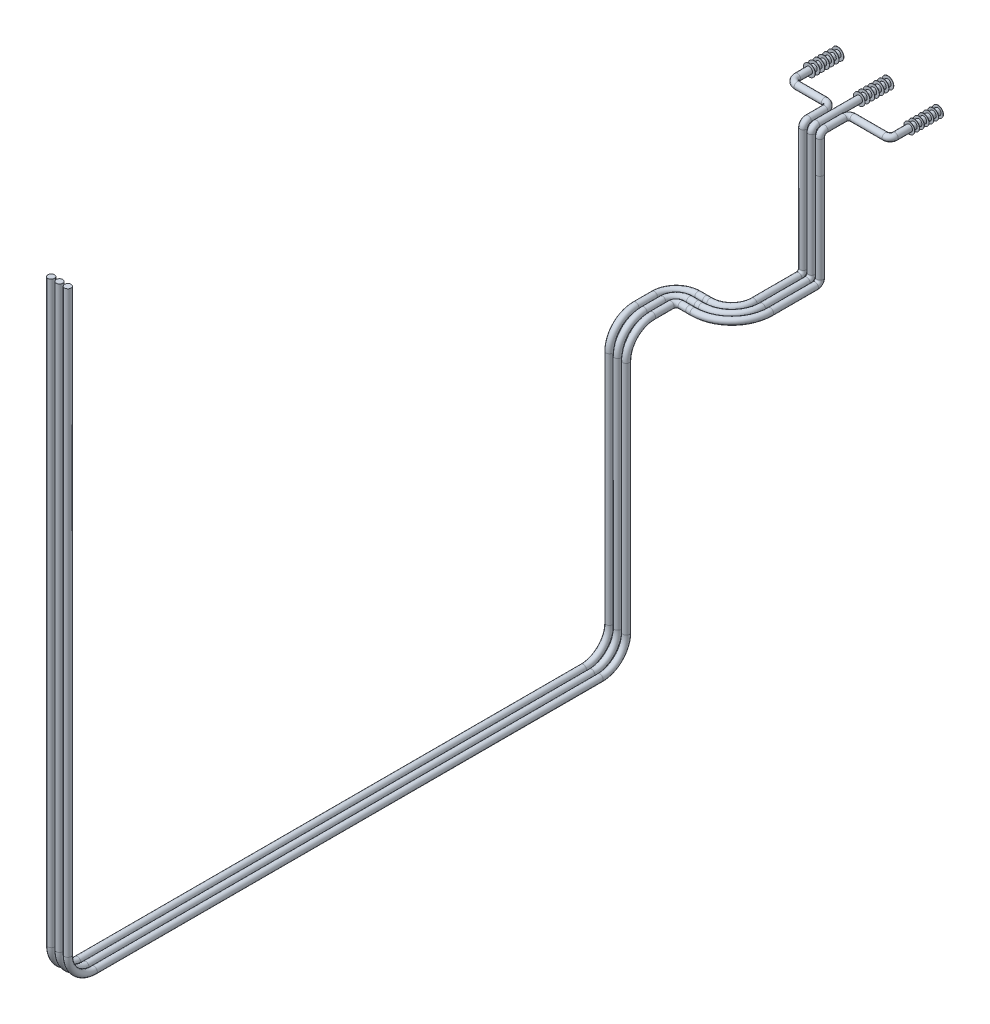
from build123d import *

# Parameters (mm, degrees)
BARRER5_PROFILE_R       = 13.7
BARRER6_PROFILE_R       = 13.7
CROQUIS41_R             = 13.7
CROQUIS62_R             = 22.870183784
CROQUIS62_R_2           = 24.36570856
CROQUIS62_R_3           = 24.738020287
SALIENTE_EXTRUIR1_DEPTH = 1
MATRIZL1_COUNT          = 7
MATRIZL1_PITCH          = 20
CROQUIS64_W             = 239.066100256
CROQUIS64_H             = 33.201144274
CORTAR_EXTRUIR1_DEPTH   = 5
CROQUIS65_R             = 13.7
CROQUIS65_R_2           = 13.697033


with BuildPart() as part:
    # Barrer5: sweep along a curve in space
    with BuildLine() as barrer5_path:
        Line((0, 0, 0), (0, 0, 170))
        ThreePointArc((0, 0, 170), (8.786796564, 0, 191.213203436), (30, 0, 200))
        Line((30, 0, 200), (145.00018, 0, 200))
        ThreePointArc((145.00018, 0, 200), (166.213383436, 0, 208.786796564), (175.00018, 0, 230))
        Line((175.00018, 0, 230), (175.00018, 0, 300))
        ThreePointArc((175.00018, 0, 300), (175.00018, -5.857864376, 314.142135624), (175.00018, -20, 320))
        Line((175.00018, -20, 320), (175.00018, -156.800061359, 320))
    # Barrer5 profile (on start of the path) → Barrer5 (sweep)
    with BuildSketch(Plane.XY):
        Circle(BARRER5_PROFILE_R)
    sweep(path=barrer5_path.line)


with BuildPart() as body_2:
    # Barrer6: sweep along a curve in space
    with BuildLine() as barrer6_path:
        Line((210, 0, 0), (210, 0, 299.997033))
        ThreePointArc((210, 0, 299.997033), (210, -5.857864376, 314.139168624), (210, -20, 319.997033))
        Line((210, -20, 319.997033), (210, -153.425324093, 319.997033))
    # Barrer6 profile (on start of the path) → Barrer6 (sweep)
    with BuildSketch(Plane(origin=(210, 0, 0), x_dir=(1, 0, 0), z_dir=(0, 0, 1))):
        Circle(BARRER6_PROFILE_R)
    sweep(path=barrer6_path.line)


with BuildPart() as body_3:
    # Barrer7: sweep along a curve in space
    with BuildLine() as barrer7_path:
        Line((420, 0, 0), (420, 0, 180))
        ThreePointArc((420, 0, 180), (414.142135624, 0, 194.142135624), (400, 0, 200))
        Line((400, 0, 200), (264.998005, 0, 200))
        ThreePointArc((264.998005, 0, 200), (250.855869376, 0, 205.857864376), (244.998005, 0, 220))
        Line((244.998005, 0, 220), (244.998005, 0, 300))
        ThreePointArc((244.998005, 0, 300), (244.998005, -5.857864376, 314.142135624), (244.998005, -20, 320))
        Line((244.998005, -20, 320), (244.998005, -158.814937218, 320))
    # Croquis41 → Barrer7 (sweep)
    with BuildSketch(Plane(origin=(0, 0, 0), x_dir=(-1, 0, 0), z_dir=(0, 0, -1))):
        with Locations((-420, 0)):
            Circle(CROQUIS41_R)
    sweep(path=barrer7_path.line)

    # Croquis62 → Saliente-Extruir1 (add)
    with BuildSketch(Plane(origin=(0, 0, 0), x_dir=(-1, 0, 0), z_dir=(0, 0, -1))):
        with Locations((-420, 0)):
            Circle(CROQUIS62_R)
        with Locations((-210, 0)):
            Circle(CROQUIS62_R_2)
        Circle(CROQUIS62_R_3)
    saliente_extruir1 = extrude(amount=SALIENTE_EXTRUIR1_DEPTH)


with BuildPart() as saliente_extruir1_piece_1:
    # of the separate pieces the step leaves, piece 1, a body of its own (saliente_extruir1_pieces)
    add(body_3.part.solids().sort_by_distance((397.129816216, 0, 0))[0])


with BuildPart() as saliente_extruir1_piece_2:
    # of the separate pieces the step leaves, piece 2, a body of its own (saliente_extruir1_pieces)
    add(body_3.part.solids().sort_by_distance((-24.738020287, 0, 0))[0])


with BuildPart() as saliente_extruir1_piece_3:
    # of the separate pieces the step leaves, piece 3, a body of its own (saliente_extruir1_pieces)
    add(body_3.part.solids().sort_by_distance((185.63429144, 0, 0))[0])


with BuildPart() as part_1:
    add(part.part)

    add(body_2.part)  # MatrizL1 merges body 2

    add(saliente_extruir1_piece_1.part)  # MatrizL1 merges Saliente-Extruir1 piece 1
    # MatrizL1: Saliente-Extruir1 ×7
    with Locations(*[(0, 0, i * MATRIZL1_PITCH) for i in range(1, MATRIZL1_COUNT)]):
        add(saliente_extruir1)

    # Croquis64 → Cortar-Extruir1 (cut)
    with BuildSketch(Plane.XZ.offset(158.814937218)):
        with Locations((191.41286696, 320.193015877)):
            Rectangle(CROQUIS64_W, CROQUIS64_H)
    extrude(amount=-CORTAR_EXTRUIR1_DEPTH, mode=Mode.SUBTRACT)

    # Barrer10: sweep along a curve in space
    with BuildLine() as barrer10_path:
        Line((175.00018, -153.425324093, 320), (175.00018, -531.355324093, 320))
        ThreePointArc((175.00018, -531.355324093, 320), (175.00018, -545.497459717, 325.857864376), (175.00018, -551.355324093, 340))
        Line((175.00018, -551.355324093, 340), (175.00018, -551.355324093, 528))
        ThreePointArc((175.00018, -551.355324093, 528), (148.054003869, -551.355324093, 593.053823869), (83.00018, -551.355324093, 620))
        Line((83.00018, -551.355324093, 620), (65.00018, -551.355324093, 620))
        Line((65.00018, -551.355324093, 620), (33.00018, -551.355324093, 620))
        ThreePointArc((33.00018, -551.355324093, 620), (-32.053643869, -551.355324093, 646.946176131), (-58.99982, -551.355324093, 712))
        Line((-58.99982, -551.355324093, 712), (-58.99982, -551.355324093, 790.185562061))
        ThreePointArc((-58.99982, -661.355324093, 900.185562061), (-58.99982, -583.573578162, 867.967307991), (-58.99982, -551.355324093, 790.185562061))
        Line((-58.99982, -661.355324093, 900.185562061), (-58.99982, -1649.448147603, 900.185562061))
        ThreePointArc((-58.99982, -1649.448147603, 900.185562061), (-58.99982, -1727.229893534, 932.40381613), (-58.99982, -1759.448147603, 1010.185562061))
        Line((-58.99982, -1759.448147603, 1010.185562061), (-58.99982, -1759.448147603, 3135.198367651))
        ThreePointArc((-58.99982, -1759.448147603, 3135.198367651), (-58.99982, -1727.229893534, 3212.980113581), (-58.99982, -1649.448147603, 3245.198367651))
        Line((-58.99982, -1649.448147603, 3245.198367651), (-58.99982, 782.622272397, 3245.198367651))
    # Croquis65 → Barrer10 (sweep)
    with BuildSketch(Plane.XZ.offset(153.425324093)):
        with Locations((175.00018, 320)):
            Circle(CROQUIS65_R)
        with Locations((210, 319.997033)):
            Circle(CROQUIS65_R)
        with Locations((244.998005, 320)):
            Circle(CROQUIS65_R_2)
    sweep(path=barrer10_path.line)


solid = Compound([saliente_extruir1_piece_2.part, saliente_extruir1_piece_3.part, part_1.part])
